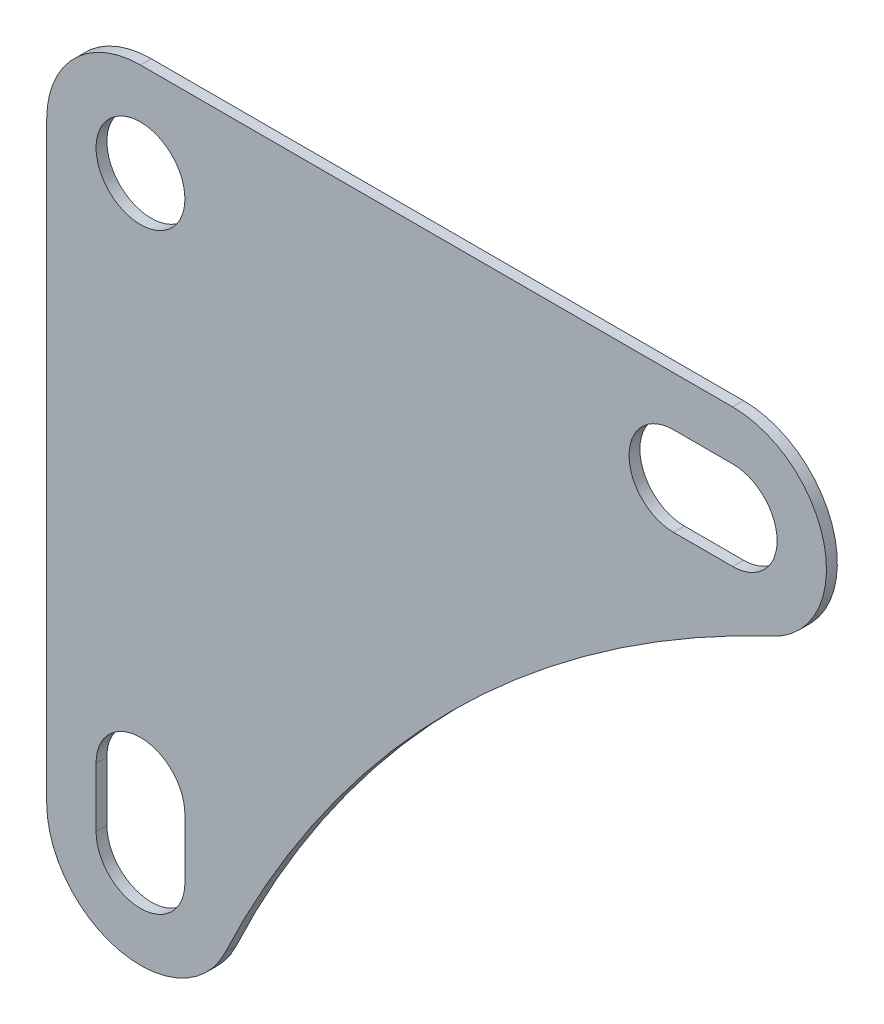
from build123d import *

# Parameters (mm, degrees)
SKETCH1_R           = 4.5
BOSS_EXTRUDE1_DEPTH = 1.1


with BuildPart() as part:
    # Sketch1 → Boss-Extrude1 (new body)
    with BuildSketch(Plane.XY):
        with BuildLine():
            Line((-9.5, -60), (-9.5, 0))
            ThreePointArc((-9.5, 0), (-6.717514421, 6.717514421), (0, 9.5))
            Line((0, 9.5), (60, 9.5))
            ThreePointArc((60, 9.5), (69.272242002, 2.067735054), (64.036324171, -8.599888789))
            ThreePointArc((64.036324171, -8.599888789), (31.466251763, -31.466251763), (8.599888789, -64.036324171))
            ThreePointArc((8.599888789, -64.036324171), (-2.067735054, -69.272242002), (-9.5, -60))
        make_face()
        Circle(SKETCH1_R, mode=Mode.SUBTRACT)
        with BuildLine():
            Line((-4.5, -60), (-4.5, -54))
            ThreePointArc((-4.5, -54), (0, -49.5), (4.5, -54))
            Line((4.5, -54), (4.5, -60))
            ThreePointArc((4.5, -60), (0, -64.5), (-4.5, -60))
        make_face(mode=Mode.SUBTRACT)
        with BuildLine():
            Line((60, -4.5), (54, -4.5))
            ThreePointArc((54, -4.5), (49.5, 0), (54, 4.5))
            Line((54, 4.5), (60, 4.5))
            ThreePointArc((60, 4.5), (64.5, 0), (60, -4.5))
        make_face(mode=Mode.SUBTRACT)
    extrude(amount=-BOSS_EXTRUDE1_DEPTH)


solid = part.part
